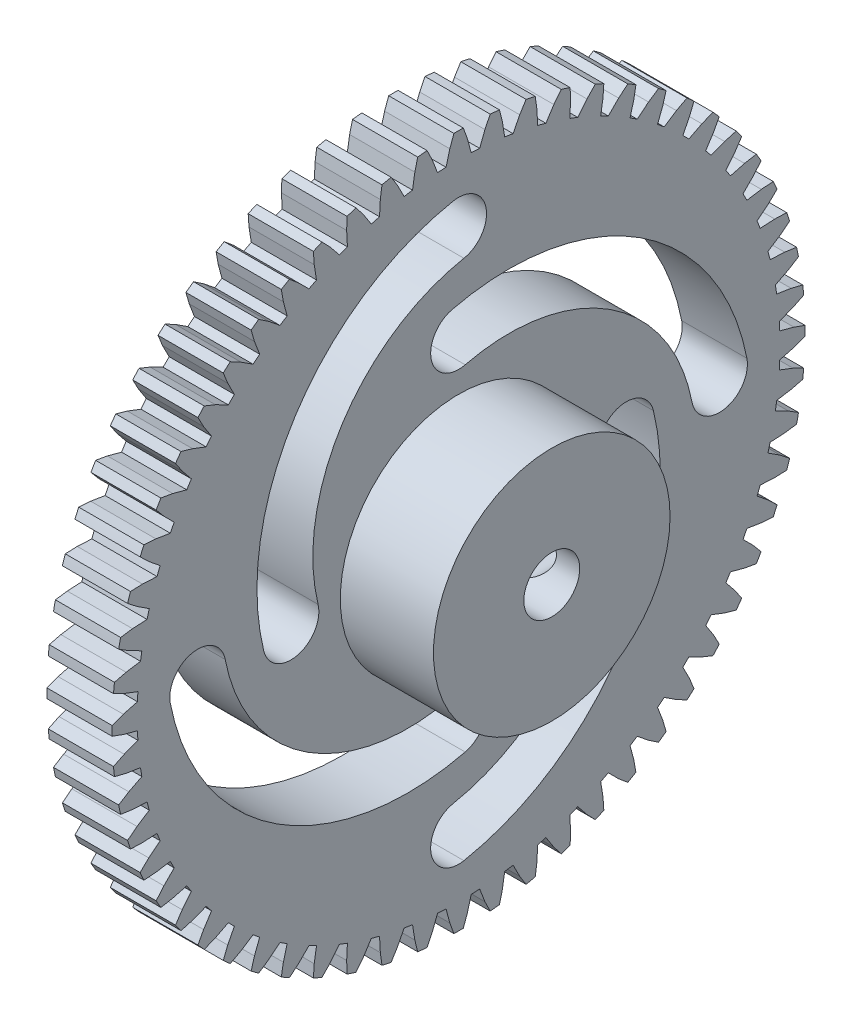
from build123d import *

# Parameters (mm, degrees)
BOSS_EXTRUDE1_DEPTH             = 3.5
SKETCH3_R                       = 6.35
BOSS_EXTRUDE2_DEPTH             = 5
F_3_0MM_CLEARANCE_DOWEL_HOLE1_D = 3
CUT_EXTRUDE5_DEPTH              = 4.5
CIRPATTERN3_COUNT               = 4
SKETCH11_R                      = 1.25
CUT_EXTRUDE6_DEPTH              = 10


with BuildPart() as part:
    # Sketch1 → Boss-Extrude1 (new body)
    with BuildSketch(Plane(origin=(6, 0, 0), x_dir=(0, 0, -1), z_dir=(1, 0, 0))):
        with BuildLine():
            Line((1.694199927, 18.52268033), (1.412210439, 17.944516201))
            Line((1.412210439, 17.944516201), (1.131353817, 17.212859685))
            ThreePointArc((1.131353817, 17.212859685), (0.902795245, 17.226359475), (0.674077629, 17.236824515))
            Line((0.674077629, 17.236824515), (0.4712385, 17.99383045))
            Line((0.4712385, 17.99383045), (0.251228388, 18.598303264))
            ThreePointArc((0.251228388, 18.598303264), (0, 18.6), (-0.251228388, 18.598303264))
            Line((-0.251228388, 18.598303264), (-0.4712385, 17.99383045))
            Line((-0.4712385, 17.99383045), (-0.674077629, 17.236824515))
            ThreePointArc((-0.674077629, 17.236824515), (-0.902795245, 17.226359475), (-1.131353817, 17.212859685))
            Line((-1.131353817, 17.212859685), (-1.412210439, 17.944516201))
            Line((-1.412210439, 17.944516201), (-1.694199927, 18.52268033))
            ThreePointArc((-1.694199927, 18.52268033), (-1.944229417, 18.498107254), (-2.193904193, 18.470159295))
            Line((-2.193904193, 18.470159295), (-2.349524451, 17.846000528))
            Line((-2.349524451, 17.846000528), (-2.472123739, 17.071939088))
            ThreePointArc((-2.472123739, 17.071939088), (-2.698494522, 17.037623875), (-2.924389914, 17.000307163))
            Line((-2.924389914, 17.000307163), (-3.280186905, 17.698598076))
            Line((-3.280186905, 17.698598076), (-3.621066233, 18.244119034))
            ThreePointArc((-3.621066233, 18.244119034), (-3.867157449, 18.193545374), (-4.112543123, 18.139652396))
            Line((-4.112543123, 18.139652396), (-4.202068521, 17.50264609))
            Line((-4.202068521, 17.50264609), (-4.243084745, 16.720009924))
            ThreePointArc((-4.243084745, 16.720009924), (-4.464628528, 16.662220503), (-4.685385782, 16.601495718))
            Line((-4.685385782, 16.601495718), (-5.112224957, 17.258770408))
            Line((-5.112224957, 17.258770408), (-5.508259379, 17.765671353))
            ThreePointArc((-5.508259379, 17.765671353), (-5.747716095, 17.689651203), (-5.986124171, 17.61040367))
            Line((-5.986124171, 17.61040367), (-6.008573849, 16.967528998))
            Line((-6.008573849, 16.967528998), (-5.967557626, 16.184892832))
            ThreePointArc((-5.967557626, 16.184892832), (-6.18184713, 16.104262357), (-6.395047584, 16.020794812))
            Line((-6.395047584, 16.020794812), (-6.888252402, 16.629852039))
            Line((-6.888252402, 16.629852039), (-7.335102883, 17.092579258))
            ThreePointArc((-7.335102883, 17.092579258), (-7.565301561, 16.991945512), (-7.79411999, 16.888211675))
            Line((-7.79411999, 16.888211675), (-7.749247985, 16.246512108))
            Line((-7.749247985, 16.246512108), (-7.626648697, 15.472450668))
            ThreePointArc((-7.626648697, 15.472450668), (-7.831336121, 15.369862542), (-8.034643906, 15.264566725))
            Line((-8.034643906, 15.264566725), (-8.588810713, 15.818733531))
            Line((-8.588810713, 15.818733531), (-9.081581465, 16.232217288))
            ThreePointArc((-9.081581465, 16.232217288), (-9.3, 16.10807251), (-9.516721799, 15.9809889))
            Line((-9.516721799, 15.9809889), (-9.405019737, 15.347495031))
            Line((-9.405019737, 15.347495031), (-9.202180608, 14.590489096))
            ThreePointArc((-9.202180608, 14.590489096), (-9.395023354, 14.467067297), (-9.586210989, 14.341096851))
            Line((-9.586210989, 14.341096851), (-10.195268216, 14.834301669))
            Line((-10.195268216, 14.834301669), (-10.72856034, 15.194011749))
            ThreePointArc((-10.72856034, 15.194011749), (-10.932805693, 15.047716095), (-11.135056412, 14.898675065))
            Line((-11.135056412, 14.898675065), (-10.957748126, 14.280327588))
            Line((-10.957748126, 14.280327588), (-10.676891504, 13.548671072))
            ThreePointArc((-10.676891504, 13.548671072), (-10.855776746, 13.405767835), (-11.032749537, 13.260502918))
            Line((-11.032749537, 13.260502918), (-11.690024227, 13.687342093))
            Line((-11.690024227, 13.687342093), (-12.257994863, 13.989337437))
            ThreePointArc((-12.257994863, 13.989337437), (-12.445829278, 13.822493754), (-12.631393017, 13.653128229))
            Line((-12.631393017, 13.653128229), (-12.390421133, 13.056701886))
            Line((-12.390421133, 13.056701886), (-12.034624141, 12.358410973))
            ThreePointArc((-12.034624141, 12.358410973), (-12.197591975, 12.197591975), (-12.358410973, 12.034624141))
            Line((-12.358410973, 12.034624141), (-13.056701886, 12.390421133))
            Line((-13.056701886, 12.390421133), (-13.653128229, 12.631393017))
            ThreePointArc((-13.653128229, 12.631393017), (-13.822493754, 12.445829278), (-13.989337437, 12.257994863))
            Line((-13.989337437, 12.257994863), (-13.687342093, 11.690024227))
            Line((-13.687342093, 11.690024227), (-13.260502918, 11.032749537))
            ThreePointArc((-13.260502918, 11.032749537), (-13.405767835, 10.855776746), (-13.548671072, 10.676891504))
            Line((-13.548671072, 10.676891504), (-14.280327588, 10.957748126))
            Line((-14.280327588, 10.957748126), (-14.898675065, 11.135056412))
            ThreePointArc((-14.898675065, 11.135056412), (-15.047716095, 10.932805693), (-15.194011749, 10.72856034))
            Line((-15.194011749, 10.72856034), (-14.834301669, 10.195268216))
            Line((-14.834301669, 10.195268216), (-14.341096851, 9.586210989))
            ThreePointArc((-14.341096851, 9.586210989), (-14.467067297, 9.395023354), (-14.590489096, 9.202180608))
            Line((-14.590489096, 9.202180608), (-15.347495031, 9.405019737))
            Line((-15.347495031, 9.405019737), (-15.9809889, 9.516721799))
            ThreePointArc((-15.9809889, 9.516721799), (-16.10807251, 9.3), (-16.232217288, 9.081581465))
            Line((-16.232217288, 9.081581465), (-15.818733531, 8.588810713))
            Line((-15.818733531, 8.588810713), (-15.264566725, 8.034643906))
            ThreePointArc((-15.264566725, 8.034643906), (-15.369862542, 7.831336121), (-15.472450668, 7.626648697))
            Line((-15.472450668, 7.626648697), (-16.246512108, 7.749247985))
            Line((-16.246512108, 7.749247985), (-16.888211675, 7.79411999))
            ThreePointArc((-16.888211675, 7.79411999), (-16.991945512, 7.565301561), (-17.092579258, 7.335102883))
            Line((-17.092579258, 7.335102883), (-16.629852039, 6.888252402))
            Line((-16.629852039, 6.888252402), (-16.020794812, 6.395047584))
            ThreePointArc((-16.020794812, 6.395047584), (-16.104262357, 6.18184713), (-16.184892832, 5.967557626))
            Line((-16.184892832, 5.967557626), (-16.967528998, 6.008573849))
            Line((-16.967528998, 6.008573849), (-17.61040367, 5.986124171))
            ThreePointArc((-17.61040367, 5.986124171), (-17.689651203, 5.747716095), (-17.765671353, 5.508259379))
            Line((-17.765671353, 5.508259379), (-17.258770408, 5.112224957))
            Line((-17.258770408, 5.112224957), (-16.601495718, 4.685385782))
            ThreePointArc((-16.601495718, 4.685385782), (-16.662220503, 4.464628528), (-16.720009924, 4.243084745))
            Line((-16.720009924, 4.243084745), (-17.50264609, 4.202068521))
            Line((-17.50264609, 4.202068521), (-18.139652396, 4.112543123))
            ThreePointArc((-18.139652396, 4.112543123), (-18.193545374, 3.867157449), (-18.244119034, 3.621066233))
            Line((-18.244119034, 3.621066233), (-17.698598076, 3.280186905))
            Line((-17.698598076, 3.280186905), (-17.000307163, 2.924389914))
            ThreePointArc((-17.000307163, 2.924389914), (-17.037623875, 2.698494522), (-17.071939088, 2.472123739))
            Line((-17.071939088, 2.472123739), (-17.846000528, 2.349524451))
            Line((-17.846000528, 2.349524451), (-18.470159295, 2.193904193))
            ThreePointArc((-18.470159295, 2.193904193), (-18.498107254, 1.944229417), (-18.52268033, 1.694199927))
            Line((-18.52268033, 1.694199927), (-17.944516201, 1.412210439))
            Line((-17.944516201, 1.412210439), (-17.212859685, 1.131353817))
            ThreePointArc((-17.212859685, 1.131353817), (-17.226359475, 0.902795245), (-17.236824515, 0.674077629))
            Line((-17.236824515, 0.674077629), (-17.99383045, 0.4712385))
            Line((-17.99383045, 0.4712385), (-18.598303264, 0.251228388))
            ThreePointArc((-18.598303264, 0.251228388), (-18.6, 0), (-18.598303264, -0.251228388))
            Line((-18.598303264, -0.251228388), (-17.99383045, -0.4712385))
            Line((-17.99383045, -0.4712385), (-17.236824515, -0.674077629))
            ThreePointArc((-17.236824515, -0.674077629), (-17.226359475, -0.902795245), (-17.212859685, -1.131353817))
            Line((-17.212859685, -1.131353817), (-17.944516201, -1.412210439))
            Line((-17.944516201, -1.412210439), (-18.52268033, -1.694199927))
            ThreePointArc((-18.52268033, -1.694199927), (-18.498107254, -1.944229417), (-18.470159295, -2.193904193))
            Line((-18.470159295, -2.193904193), (-17.846000528, -2.349524451))
            Line((-17.846000528, -2.349524451), (-17.071939088, -2.472123739))
            ThreePointArc((-17.071939088, -2.472123739), (-17.037623875, -2.698494522), (-17.000307163, -2.924389914))
            Line((-17.000307163, -2.924389914), (-17.698598076, -3.280186905))
            Line((-17.698598076, -3.280186905), (-18.244119034, -3.621066233))
            ThreePointArc((-18.244119034, -3.621066233), (-18.193545374, -3.867157449), (-18.139652396, -4.112543123))
            Line((-18.139652396, -4.112543123), (-17.50264609, -4.202068521))
            Line((-17.50264609, -4.202068521), (-16.720009924, -4.243084745))
            ThreePointArc((-16.720009924, -4.243084745), (-16.662220503, -4.464628528), (-16.601495718, -4.685385782))
            Line((-16.601495718, -4.685385782), (-17.258770408, -5.112224957))
            Line((-17.258770408, -5.112224957), (-17.765671353, -5.508259379))
            ThreePointArc((-17.765671353, -5.508259379), (-17.689651203, -5.747716095), (-17.61040367, -5.986124171))
            Line((-17.61040367, -5.986124171), (-16.967528998, -6.008573849))
            Line((-16.967528998, -6.008573849), (-16.184892832, -5.967557626))
            ThreePointArc((-16.184892832, -5.967557626), (-16.104262357, -6.18184713), (-16.020794812, -6.395047584))
            Line((-16.020794812, -6.395047584), (-16.629852039, -6.888252402))
            Line((-16.629852039, -6.888252402), (-17.092579258, -7.335102883))
            ThreePointArc((-17.092579258, -7.335102883), (-16.991945512, -7.565301561), (-16.888211675, -7.79411999))
            Line((-16.888211675, -7.79411999), (-16.246512108, -7.749247985))
            Line((-16.246512108, -7.749247985), (-15.472450668, -7.626648697))
            ThreePointArc((-15.472450668, -7.626648697), (-15.369862542, -7.831336121), (-15.264566725, -8.034643906))
            Line((-15.264566725, -8.034643906), (-15.818733531, -8.588810713))
            Line((-15.818733531, -8.588810713), (-16.232217288, -9.081581465))
            ThreePointArc((-16.232217288, -9.081581465), (-16.10807251, -9.3), (-15.9809889, -9.516721799))
            Line((-15.9809889, -9.516721799), (-15.347495031, -9.405019737))
            Line((-15.347495031, -9.405019737), (-14.590489096, -9.202180608))
            ThreePointArc((-14.590489096, -9.202180608), (-14.467067297, -9.395023354), (-14.341096851, -9.586210989))
            Line((-14.341096851, -9.586210989), (-14.834301669, -10.195268216))
            Line((-14.834301669, -10.195268216), (-15.194011749, -10.72856034))
            ThreePointArc((-15.194011749, -10.72856034), (-15.047716095, -10.932805693), (-14.898675065, -11.135056412))
            Line((-14.898675065, -11.135056412), (-14.280327588, -10.957748126))
            Line((-14.280327588, -10.957748126), (-13.548671072, -10.676891504))
            ThreePointArc((-13.548671072, -10.676891504), (-13.405767835, -10.855776746), (-13.260502918, -11.032749537))
            Line((-13.260502918, -11.032749537), (-13.687342093, -11.690024227))
            Line((-13.687342093, -11.690024227), (-13.989337437, -12.257994863))
            ThreePointArc((-13.989337437, -12.257994863), (-13.822493754, -12.445829278), (-13.653128229, -12.631393017))
            Line((-13.653128229, -12.631393017), (-13.056701886, -12.390421133))
            Line((-13.056701886, -12.390421133), (-12.358410973, -12.034624141))
            ThreePointArc((-12.358410973, -12.034624141), (-12.197591975, -12.197591975), (-12.034624141, -12.358410973))
            Line((-12.034624141, -12.358410973), (-12.390421133, -13.056701886))
            Line((-12.390421133, -13.056701886), (-12.631393017, -13.653128229))
            ThreePointArc((-12.631393017, -13.653128229), (-12.445829278, -13.822493754), (-12.257994863, -13.989337437))
            Line((-12.257994863, -13.989337437), (-11.690024227, -13.687342093))
            Line((-11.690024227, -13.687342093), (-11.032749537, -13.260502918))
            ThreePointArc((-11.032749537, -13.260502918), (-10.855776746, -13.405767835), (-10.676891504, -13.548671072))
            Line((-10.676891504, -13.548671072), (-10.957748126, -14.280327588))
            Line((-10.957748126, -14.280327588), (-11.135056412, -14.898675065))
            ThreePointArc((-11.135056412, -14.898675065), (-10.932805693, -15.047716095), (-10.72856034, -15.194011749))
            Line((-10.72856034, -15.194011749), (-10.195268216, -14.834301669))
            Line((-10.195268216, -14.834301669), (-9.586210989, -14.341096851))
            ThreePointArc((-9.586210989, -14.341096851), (-9.395023354, -14.467067297), (-9.202180608, -14.590489096))
            Line((-9.202180608, -14.590489096), (-9.405019737, -15.347495031))
            Line((-9.405019737, -15.347495031), (-9.516721799, -15.9809889))
            ThreePointArc((-9.516721799, -15.9809889), (-9.3, -16.10807251), (-9.081581465, -16.232217288))
            Line((-9.081581465, -16.232217288), (-8.588810713, -15.818733531))
            Line((-8.588810713, -15.818733531), (-8.034643906, -15.264566725))
            ThreePointArc((-8.034643906, -15.264566725), (-7.831336121, -15.369862542), (-7.626648697, -15.472450668))
            Line((-7.626648697, -15.472450668), (-7.749247985, -16.246512108))
            Line((-7.749247985, -16.246512108), (-7.79411999, -16.888211675))
            ThreePointArc((-7.79411999, -16.888211675), (-7.565301561, -16.991945512), (-7.335102883, -17.092579258))
            Line((-7.335102883, -17.092579258), (-6.888252402, -16.629852039))
            Line((-6.888252402, -16.629852039), (-6.395047584, -16.020794812))
            ThreePointArc((-6.395047584, -16.020794812), (-6.18184713, -16.104262357), (-5.967557626, -16.184892832))
            Line((-5.967557626, -16.184892832), (-6.008573849, -16.967528998))
            Line((-6.008573849, -16.967528998), (-5.986124171, -17.61040367))
            ThreePointArc((-5.986124171, -17.61040367), (-5.747716095, -17.689651203), (-5.508259379, -17.765671353))
            Line((-5.508259379, -17.765671353), (-5.112224957, -17.258770408))
            Line((-5.112224957, -17.258770408), (-4.685385782, -16.601495718))
            ThreePointArc((-4.685385782, -16.601495718), (-4.464628528, -16.662220503), (-4.243084745, -16.720009924))
            Line((-4.243084745, -16.720009924), (-4.202068521, -17.50264609))
            Line((-4.202068521, -17.50264609), (-4.112543123, -18.139652396))
            ThreePointArc((-4.112543123, -18.139652396), (-3.867157449, -18.193545374), (-3.621066233, -18.244119034))
            Line((-3.621066233, -18.244119034), (-3.280186905, -17.698598076))
            Line((-3.280186905, -17.698598076), (-2.924389914, -17.000307163))
            ThreePointArc((-2.924389914, -17.000307163), (-2.698494522, -17.037623875), (-2.472123739, -17.071939088))
            Line((-2.472123739, -17.071939088), (-2.349524451, -17.846000528))
            Line((-2.349524451, -17.846000528), (-2.193904193, -18.470159295))
            ThreePointArc((-2.193904193, -18.470159295), (-1.944229417, -18.498107254), (-1.694199927, -18.52268033))
            Line((-1.694199927, -18.52268033), (-1.412210439, -17.944516201))
            Line((-1.412210439, -17.944516201), (-1.131353817, -17.212859685))
            ThreePointArc((-1.131353817, -17.212859685), (-0.902795245, -17.226359475), (-0.674077629, -17.236824515))
            Line((-0.674077629, -17.236824515), (-0.4712385, -17.99383045))
            Line((-0.4712385, -17.99383045), (-0.251228388, -18.598303264))
            ThreePointArc((-0.251228388, -18.598303264), (0, -18.6), (0.251228388, -18.598303264))
            Line((0.251228388, -18.598303264), (0.4712385, -17.99383045))
            Line((0.4712385, -17.99383045), (0.674077629, -17.236824515))
            ThreePointArc((0.674077629, -17.236824515), (0.902795245, -17.226359475), (1.131353817, -17.212859685))
            Line((1.131353817, -17.212859685), (1.412210439, -17.944516201))
            Line((1.412210439, -17.944516201), (1.694199927, -18.52268033))
            ThreePointArc((1.694199927, -18.52268033), (1.944229417, -18.498107254), (2.193904193, -18.470159295))
            Line((2.193904193, -18.470159295), (2.349524451, -17.846000528))
            Line((2.349524451, -17.846000528), (2.472123739, -17.071939088))
            ThreePointArc((2.472123739, -17.071939088), (2.698494522, -17.037623875), (2.924389914, -17.000307163))
            Line((2.924389914, -17.000307163), (3.280186905, -17.698598076))
            Line((3.280186905, -17.698598076), (3.621066233, -18.244119034))
            ThreePointArc((3.621066233, -18.244119034), (3.867157449, -18.193545374), (4.112543123, -18.139652396))
            Line((4.112543123, -18.139652396), (4.202068521, -17.50264609))
            Line((4.202068521, -17.50264609), (4.243084745, -16.720009924))
            ThreePointArc((4.243084745, -16.720009924), (4.464628528, -16.662220503), (4.685385782, -16.601495718))
            Line((4.685385782, -16.601495718), (5.112224957, -17.258770408))
            Line((5.112224957, -17.258770408), (5.508259379, -17.765671353))
            ThreePointArc((5.508259379, -17.765671353), (5.747716095, -17.689651203), (5.986124171, -17.61040367))
            Line((5.986124171, -17.61040367), (6.008573849, -16.967528998))
            Line((6.008573849, -16.967528998), (5.967557626, -16.184892832))
            ThreePointArc((5.967557626, -16.184892832), (6.18184713, -16.104262357), (6.395047584, -16.020794812))
            Line((6.395047584, -16.020794812), (6.888252402, -16.629852039))
            Line((6.888252402, -16.629852039), (7.335102883, -17.092579258))
            ThreePointArc((7.335102883, -17.092579258), (7.565301561, -16.991945512), (7.79411999, -16.888211675))
            Line((7.79411999, -16.888211675), (7.749247985, -16.246512108))
            Line((7.749247985, -16.246512108), (7.626648697, -15.472450668))
            ThreePointArc((7.626648697, -15.472450668), (7.831336121, -15.369862542), (8.034643906, -15.264566725))
            Line((8.034643906, -15.264566725), (8.588810713, -15.818733531))
            Line((8.588810713, -15.818733531), (9.081581465, -16.232217288))
            ThreePointArc((9.081581465, -16.232217288), (9.3, -16.10807251), (9.516721799, -15.9809889))
            Line((9.516721799, -15.9809889), (9.405019737, -15.347495031))
            Line((9.405019737, -15.347495031), (9.202180608, -14.590489096))
            ThreePointArc((9.202180608, -14.590489096), (9.395023354, -14.467067297), (9.586210989, -14.341096851))
            Line((9.586210989, -14.341096851), (10.195268216, -14.834301669))
            Line((10.195268216, -14.834301669), (10.72856034, -15.194011749))
            ThreePointArc((10.72856034, -15.194011749), (10.932805693, -15.047716095), (11.135056412, -14.898675065))
            Line((11.135056412, -14.898675065), (10.957748126, -14.280327588))
            Line((10.957748126, -14.280327588), (10.676891504, -13.548671072))
            ThreePointArc((10.676891504, -13.548671072), (10.855776746, -13.405767835), (11.032749537, -13.260502918))
            Line((11.032749537, -13.260502918), (11.690024227, -13.687342093))
            Line((11.690024227, -13.687342093), (12.257994863, -13.989337437))
            ThreePointArc((12.257994863, -13.989337437), (12.445829278, -13.822493754), (12.631393017, -13.653128229))
            Line((12.631393017, -13.653128229), (12.390421133, -13.056701886))
            Line((12.390421133, -13.056701886), (12.034624141, -12.358410973))
            ThreePointArc((12.034624141, -12.358410973), (12.197591975, -12.197591975), (12.358410973, -12.034624141))
            Line((12.358410973, -12.034624141), (13.056701886, -12.390421133))
            Line((13.056701886, -12.390421133), (13.653128229, -12.631393017))
            ThreePointArc((13.653128229, -12.631393017), (13.822493754, -12.445829278), (13.989337437, -12.257994863))
            Line((13.989337437, -12.257994863), (13.687342093, -11.690024227))
            Line((13.687342093, -11.690024227), (13.260502918, -11.032749537))
            ThreePointArc((13.260502918, -11.032749537), (13.405767835, -10.855776746), (13.548671072, -10.676891504))
            Line((13.548671072, -10.676891504), (14.280327588, -10.957748126))
            Line((14.280327588, -10.957748126), (14.898675065, -11.135056412))
            ThreePointArc((14.898675065, -11.135056412), (15.047716095, -10.932805693), (15.194011749, -10.72856034))
            Line((15.194011749, -10.72856034), (14.834301669, -10.195268216))
            Line((14.834301669, -10.195268216), (14.341096851, -9.586210989))
            ThreePointArc((14.341096851, -9.586210989), (14.467067297, -9.395023354), (14.590489096, -9.202180608))
            Line((14.590489096, -9.202180608), (15.347495031, -9.405019737))
            Line((15.347495031, -9.405019737), (15.9809889, -9.516721799))
            ThreePointArc((15.9809889, -9.516721799), (16.10807251, -9.3), (16.232217288, -9.081581465))
            Line((16.232217288, -9.081581465), (15.818733531, -8.588810713))
            Line((15.818733531, -8.588810713), (15.264566725, -8.034643906))
            ThreePointArc((15.264566725, -8.034643906), (15.369862542, -7.831336121), (15.472450668, -7.626648697))
            Line((15.472450668, -7.626648697), (16.246512108, -7.749247985))
            Line((16.246512108, -7.749247985), (16.888211675, -7.79411999))
            ThreePointArc((16.888211675, -7.79411999), (16.991945512, -7.565301561), (17.092579258, -7.335102883))
            Line((17.092579258, -7.335102883), (16.629852039, -6.888252402))
            Line((16.629852039, -6.888252402), (16.020794812, -6.395047584))
            ThreePointArc((16.020794812, -6.395047584), (16.104262357, -6.18184713), (16.184892832, -5.967557626))
            Line((16.184892832, -5.967557626), (16.967528998, -6.008573849))
            Line((16.967528998, -6.008573849), (17.61040367, -5.986124171))
            ThreePointArc((17.61040367, -5.986124171), (17.689651203, -5.747716095), (17.765671353, -5.508259379))
            Line((17.765671353, -5.508259379), (17.258770408, -5.112224957))
            Line((17.258770408, -5.112224957), (16.601495718, -4.685385782))
            ThreePointArc((16.601495718, -4.685385782), (16.662220503, -4.464628528), (16.720009924, -4.243084745))
            Line((16.720009924, -4.243084745), (17.50264609, -4.202068521))
            Line((17.50264609, -4.202068521), (18.139652396, -4.112543123))
            ThreePointArc((18.139652396, -4.112543123), (18.193545374, -3.867157449), (18.244119034, -3.621066233))
            Line((18.244119034, -3.621066233), (17.698598076, -3.280186905))
            Line((17.698598076, -3.280186905), (17.000307163, -2.924389914))
            ThreePointArc((17.000307163, -2.924389914), (17.037623875, -2.698494522), (17.071939088, -2.472123739))
            Line((17.071939088, -2.472123739), (17.846000528, -2.349524451))
            Line((17.846000528, -2.349524451), (18.470159295, -2.193904193))
            ThreePointArc((18.470159295, -2.193904193), (18.498107254, -1.944229417), (18.52268033, -1.694199927))
            Line((18.52268033, -1.694199927), (17.944516201, -1.412210439))
            Line((17.944516201, -1.412210439), (17.212859685, -1.131353817))
            ThreePointArc((17.212859685, -1.131353817), (17.226359475, -0.902795245), (17.236824515, -0.674077629))
            Line((17.236824515, -0.674077629), (17.99383045, -0.4712385))
            Line((17.99383045, -0.4712385), (18.598303264, -0.251228388))
            ThreePointArc((18.598303264, -0.251228388), (18.6, 0), (18.598303264, 0.251228388))
            Line((18.598303264, 0.251228388), (17.99383045, 0.4712385))
            Line((17.99383045, 0.4712385), (17.236824515, 0.674077629))
            ThreePointArc((17.236824515, 0.674077629), (17.226359475, 0.902795245), (17.212859685, 1.131353817))
            Line((17.212859685, 1.131353817), (17.944516201, 1.412210439))
            Line((17.944516201, 1.412210439), (18.52268033, 1.694199927))
            ThreePointArc((18.52268033, 1.694199927), (18.498107254, 1.944229417), (18.470159295, 2.193904193))
            Line((18.470159295, 2.193904193), (17.846000528, 2.349524451))
            Line((17.846000528, 2.349524451), (17.071939088, 2.472123739))
            ThreePointArc((17.071939088, 2.472123739), (17.037623875, 2.698494522), (17.000307163, 2.924389914))
            Line((17.000307163, 2.924389914), (17.698598076, 3.280186905))
            Line((17.698598076, 3.280186905), (18.244119034, 3.621066233))
            ThreePointArc((18.244119034, 3.621066233), (18.193545374, 3.867157449), (18.139652396, 4.112543123))
            Line((18.139652396, 4.112543123), (17.50264609, 4.202068521))
            Line((17.50264609, 4.202068521), (16.720009924, 4.243084745))
            ThreePointArc((16.720009924, 4.243084745), (16.662220503, 4.464628528), (16.601495718, 4.685385782))
            Line((16.601495718, 4.685385782), (17.258770408, 5.112224957))
            Line((17.258770408, 5.112224957), (17.765671353, 5.508259379))
            ThreePointArc((17.765671353, 5.508259379), (17.689651203, 5.747716095), (17.61040367, 5.986124171))
            Line((17.61040367, 5.986124171), (16.967528998, 6.008573849))
            Line((16.967528998, 6.008573849), (16.184892832, 5.967557626))
            ThreePointArc((16.184892832, 5.967557626), (16.104262357, 6.18184713), (16.020794812, 6.395047584))
            Line((16.020794812, 6.395047584), (16.629852039, 6.888252402))
            Line((16.629852039, 6.888252402), (17.092579258, 7.335102883))
            ThreePointArc((17.092579258, 7.335102883), (16.991945512, 7.565301561), (16.888211675, 7.79411999))
            Line((16.888211675, 7.79411999), (16.246512108, 7.749247985))
            Line((16.246512108, 7.749247985), (15.472450668, 7.626648697))
            ThreePointArc((15.472450668, 7.626648697), (15.369862542, 7.831336121), (15.264566725, 8.034643906))
            Line((15.264566725, 8.034643906), (15.818733531, 8.588810713))
            Line((15.818733531, 8.588810713), (16.232217288, 9.081581465))
            ThreePointArc((16.232217288, 9.081581465), (16.10807251, 9.3), (15.9809889, 9.516721799))
            Line((15.9809889, 9.516721799), (15.347495031, 9.405019737))
            Line((15.347495031, 9.405019737), (14.590489096, 9.202180608))
            ThreePointArc((14.590489096, 9.202180608), (14.467067297, 9.395023354), (14.341096851, 9.586210989))
            Line((14.341096851, 9.586210989), (14.834301669, 10.195268216))
            Line((14.834301669, 10.195268216), (15.194011749, 10.72856034))
            ThreePointArc((15.194011749, 10.72856034), (15.047716095, 10.932805693), (14.898675065, 11.135056412))
            Line((14.898675065, 11.135056412), (14.280327588, 10.957748126))
            Line((14.280327588, 10.957748126), (13.548671072, 10.676891504))
            ThreePointArc((13.548671072, 10.676891504), (13.405767835, 10.855776746), (13.260502918, 11.032749537))
            Line((13.260502918, 11.032749537), (13.687342093, 11.690024227))
            Line((13.687342093, 11.690024227), (13.989337437, 12.257994863))
            ThreePointArc((13.989337437, 12.257994863), (13.822493754, 12.445829278), (13.653128229, 12.631393017))
            Line((13.653128229, 12.631393017), (13.056701886, 12.390421133))
            Line((13.056701886, 12.390421133), (12.358410973, 12.034624141))
            ThreePointArc((12.358410973, 12.034624141), (12.197591975, 12.197591975), (12.034624141, 12.358410973))
            Line((12.034624141, 12.358410973), (12.390421133, 13.056701886))
            Line((12.390421133, 13.056701886), (12.631393017, 13.653128229))
            ThreePointArc((12.631393017, 13.653128229), (12.445829278, 13.822493754), (12.257994863, 13.989337437))
            Line((12.257994863, 13.989337437), (11.690024227, 13.687342093))
            Line((11.690024227, 13.687342093), (11.032749537, 13.260502918))
            ThreePointArc((11.032749537, 13.260502918), (10.855776746, 13.405767835), (10.676891504, 13.548671072))
            Line((10.676891504, 13.548671072), (10.957748126, 14.280327588))
            Line((10.957748126, 14.280327588), (11.135056412, 14.898675065))
            ThreePointArc((11.135056412, 14.898675065), (10.932805693, 15.047716095), (10.72856034, 15.194011749))
            Line((10.72856034, 15.194011749), (10.195268216, 14.834301669))
            Line((10.195268216, 14.834301669), (9.586210989, 14.341096851))
            ThreePointArc((9.586210989, 14.341096851), (9.395023354, 14.467067297), (9.202180608, 14.590489096))
            Line((9.202180608, 14.590489096), (9.405019737, 15.347495031))
            Line((9.405019737, 15.347495031), (9.516721799, 15.9809889))
            ThreePointArc((9.516721799, 15.9809889), (9.3, 16.10807251), (9.081581465, 16.232217288))
            Line((9.081581465, 16.232217288), (8.588810713, 15.818733531))
            Line((8.588810713, 15.818733531), (8.034643906, 15.264566725))
            ThreePointArc((8.034643906, 15.264566725), (7.831336121, 15.369862542), (7.626648697, 15.472450668))
            Line((7.626648697, 15.472450668), (7.749247985, 16.246512108))
            Line((7.749247985, 16.246512108), (7.79411999, 16.888211675))
            ThreePointArc((7.79411999, 16.888211675), (7.565301561, 16.991945512), (7.335102883, 17.092579258))
            Line((7.335102883, 17.092579258), (6.888252402, 16.629852039))
            Line((6.888252402, 16.629852039), (6.395047584, 16.020794812))
            ThreePointArc((6.395047584, 16.020794812), (6.18184713, 16.104262357), (5.967557626, 16.184892832))
            Line((5.967557626, 16.184892832), (6.008573849, 16.967528998))
            Line((6.008573849, 16.967528998), (5.986124171, 17.61040367))
            ThreePointArc((5.986124171, 17.61040367), (5.747716095, 17.689651203), (5.508259379, 17.765671353))
            Line((5.508259379, 17.765671353), (5.112224957, 17.258770408))
            Line((5.112224957, 17.258770408), (4.685385782, 16.601495718))
            ThreePointArc((4.685385782, 16.601495718), (4.464628528, 16.662220503), (4.243084745, 16.720009924))
            Line((4.243084745, 16.720009924), (4.202068521, 17.50264609))
            Line((4.202068521, 17.50264609), (4.112543123, 18.139652396))
            ThreePointArc((4.112543123, 18.139652396), (3.867157449, 18.193545374), (3.621066233, 18.244119034))
            Line((3.621066233, 18.244119034), (3.280186905, 17.698598076))
            Line((3.280186905, 17.698598076), (2.924389914, 17.000307163))
            ThreePointArc((2.924389914, 17.000307163), (2.698494522, 17.037623875), (2.472123739, 17.071939088))
            Line((2.472123739, 17.071939088), (2.349524451, 17.846000528))
            Line((2.349524451, 17.846000528), (2.193904193, 18.470159295))
            ThreePointArc((2.193904193, 18.470159295), (1.944229417, 18.498107254), (1.694199927, 18.52268033))
        make_face()
    extrude(amount=-BOSS_EXTRUDE1_DEPTH)

    # Sketch3 → Boss-Extrude2 (add)
    with BuildSketch(Plane(origin=(6, 0, 0), x_dir=(0, 0, -1), z_dir=(1, 0, 0))):
        Circle(SKETCH3_R)
    extrude(amount=BOSS_EXTRUDE2_DEPTH)

    # Ø3.0mm Clearance Dowel Hole1 (through all)
    with Locations(Plane(origin=(11, 0, 0), x_dir=(0, 0, -1), z_dir=(1, 0, 0))):
        with Locations((0, 0)):
            Hole(F_3_0MM_CLEARANCE_DOWEL_HOLE1_D / 2)

    # Sketch10 → Cut-Extrude5 (cut, through all)
    with BuildSketch(Plane(origin=(6, 0, 0), x_dir=(0, 0, -1), z_dir=(1, 0, 0))):
        with BuildLine():
            ThreePointArc((0.283910499, 12.527113437), (1.472886563, 14.283910499), (-0.283910499, 15.472886563))
            ThreePointArc((-0.283910499, 15.472886563), (-8.758673018, 9.737718369), (-10.457823543, -0.353200393))
            ThreePointArc((-10.457823543, -0.353200393), (-8.646799607, -1.457823543), (-7.542176457, 0.353200393))
            ThreePointArc((-7.542176457, 0.353200393), (-6.235137592, 8.115445595), (0.283910499, 12.527113437))
        make_face()
    cut_extrude5 = extrude(amount=-CUT_EXTRUDE5_DEPTH, mode=Mode.SUBTRACT)

    # CirPattern3: Cut-Extrude5 ×4 about axis
    cirpattern3_axis = Axis((0, 0, 0), (1, 0, 0))
    for i in range(1, CIRPATTERN3_COUNT):
        add(cut_extrude5.rotate(cirpattern3_axis, i * 360 / CIRPATTERN3_COUNT), mode=Mode.SUBTRACT)

    # Sketch11 → Cut-Extrude6 (cut)
    with BuildSketch(Plane.XY):
        with Locations((8.5, 0)):
            Circle(SKETCH11_R)
    extrude(amount=-CUT_EXTRUDE6_DEPTH, mode=Mode.SUBTRACT)


solid = part.part
